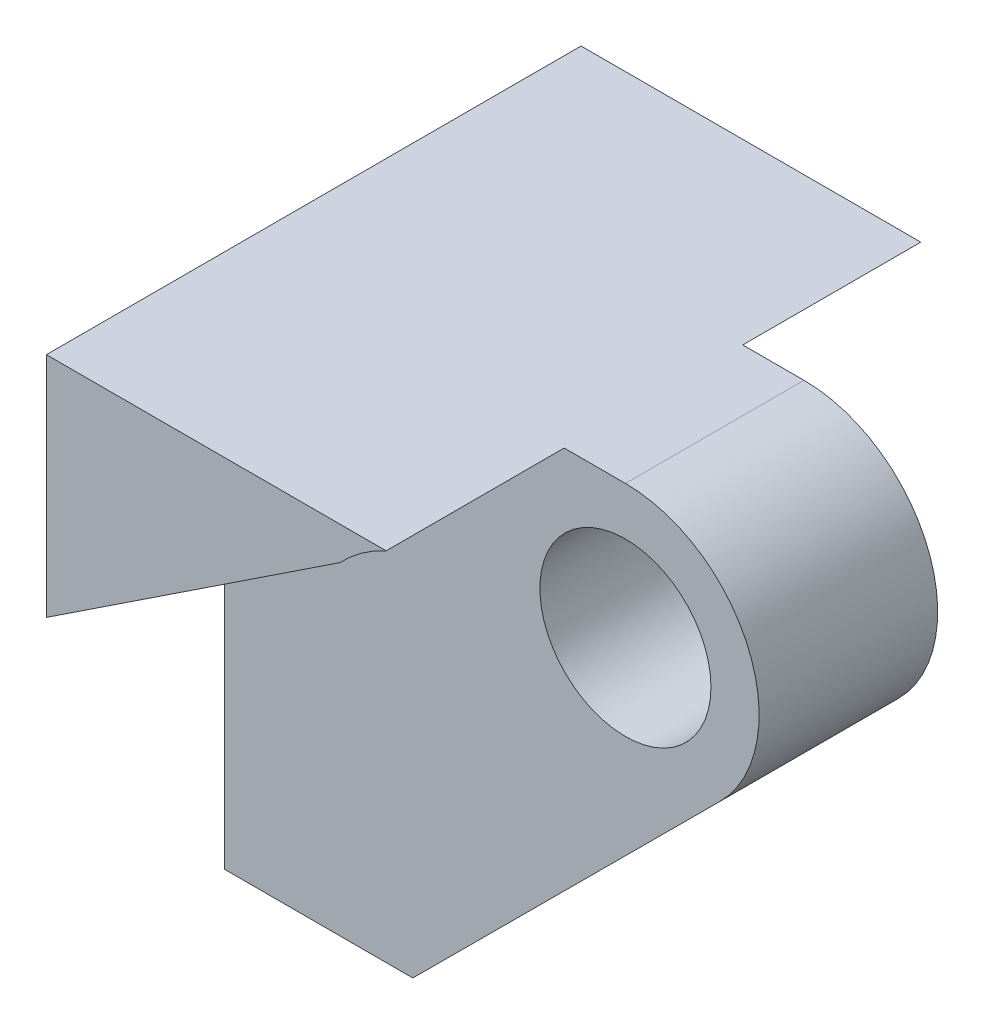
from build123d import *

# Parameters (mm, degrees)
SKETCH1_R           = 1.6
BOSS_EXTRUDE1_DEPTH = 5
CUT_EXTRUDE2_DEPTH  = 3.33


with BuildPart() as part:
    # Sketch1 → Boss-Extrude1 (new body)
    with BuildSketch(Plane.XY):
        with BuildLine():
            Line((0, 2.5), (-7.5, 2.5))
            Line((-7.5, 2.5), (-7.5, -7.5))
            Line((-7.5, -7.5), (-3.976969112, -7.5))
            Line((-3.976969112, -7.5), (1.765839775, -1.769692032))
            ThreePointArc((1.765839775, -1.769692032), (2.310219695, 0.955450135), (0, 2.5))
        make_face()
        Circle(SKETCH1_R, mode=Mode.SUBTRACT)
    extrude(amount=BOSS_EXTRUDE1_DEPTH)

    # Sketch4 → Cut-Extrude2 (cut)
    with BuildSketch(Plane.XY.offset(5)):
        with BuildLine():
            Line((1.943040083, -1.946046052), (-3.82334364, -7.91054561))
            Line((-3.82334364, -7.91054561), (-8.510185697, -7.91054561))
            Line((-8.510185697, -7.91054561), (-8.510185697, -2.424183437))
            Line((-8.510185697, -2.424183437), (-2.010547232, 1.876219558))
            ThreePointArc((-2.010547232, 1.876219558), (1.911430852, 1.977101945), (1.943040083, -1.946046052))
        make_face()
    extrude(amount=-CUT_EXTRUDE2_DEPTH, mode=Mode.SUBTRACT)

    # Mirror1: part across plane


with BuildPart() as part_1:
    add(part.part)
    add(part.part.mirror(Plane.XY))


solid = part_1.part
